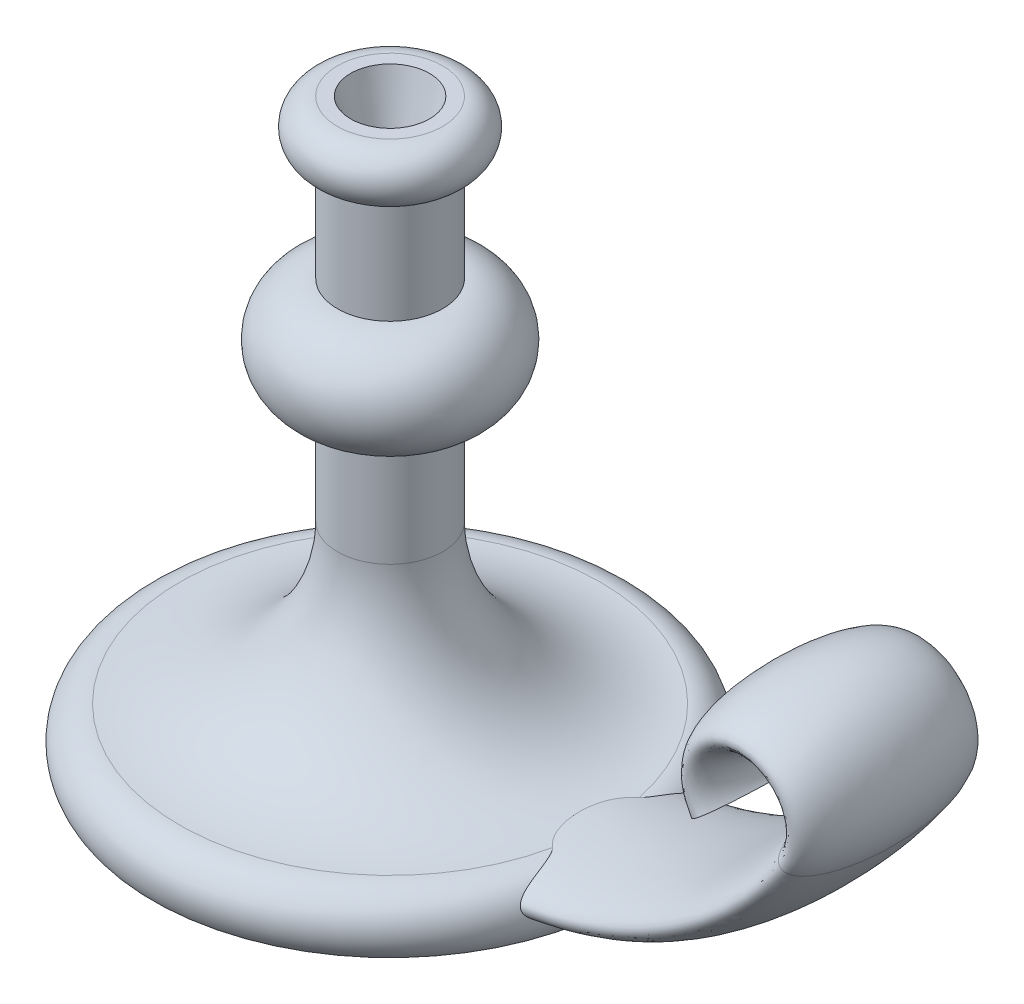
from build123d import *

# Parameters (mm, degrees)
SKETCH3_RX         = 35
SKETCH3_RY         = 10
SKETCH6_R          = 15
CUT_EXTRUDE1_DEPTH = 25
CUT_EXTRUDE1_TAPER = 15


with BuildPart() as part:
    # Sketch1 → Revolve1 (revolve)
    with BuildSketch(Plane.XY):
        with BuildLine():
            Line((0, 0), (0, 220))
            Line((0, 220), (20, 220))
            ThreePointArc((20, 220), (30, 210), (20, 200))
            Line((20, 200), (20, 160))
            ThreePointArc((20, 160), (40, 140), (20, 120))
            Line((20, 120), (20, 80))
            ThreePointArc((20, 80), (37.573593129, 37.573593129), (80, 20))
            ThreePointArc((80, 20), (91.180339887, 13.090169944), (90, 0))
            Line((90, 0), (0, 0))
        make_face()
    revolve(axis=Axis((0, 0, 0), (0, 1, 0)))

    # Sweep2: sweep along a path in Sketch2
    with BuildLine(Plane.XY) as sweep2_path:
        Line((0, 10), (60, 10))
        ThreePointArc((60, 10), (129.821200219, 27.240819526), (183.592070943, 75))
        ThreePointArc((183.592070943, 75), (167.113128151, 106.333333333), (150.634185358, 75))
    # Sketch3 → Sweep2 (sweep)
    with BuildSketch(Plane(origin=(0, 0, 0), x_dir=(0, 0, -1), z_dir=(1, 0, 0))):
        with Locations((0, 10)):
            Ellipse(SKETCH3_RX, SKETCH3_RY)
    sweep(path=sweep2_path.line)

    # Sketch6 → Cut-Extrude1 (cut)
    with BuildSketch(Plane(origin=(0, 220, 0), x_dir=(1, 0, 0), z_dir=(0, 1, 0))):
        Circle(SKETCH6_R)
    extrude(amount=-CUT_EXTRUDE1_DEPTH, taper=CUT_EXTRUDE1_TAPER, mode=Mode.SUBTRACT)


solid = part.part
